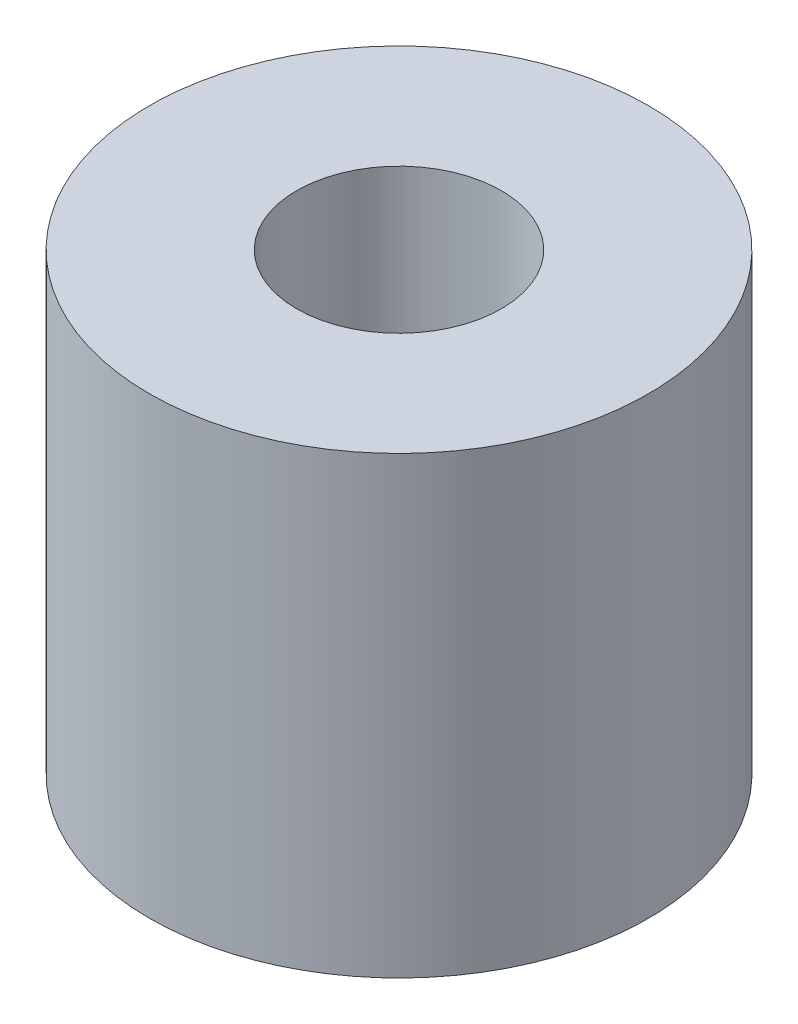
from build123d import *

# Parameters (mm, degrees)
SKETCH11_R          = 3.9
SKETCH11_R_2        = 1.6
BOSS_EXTRUDE6_DEPTH = 7.1


with BuildPart() as part:
    # Sketch11 → Boss-Extrude6 (new body)
    with BuildSketch(Plane(origin=(0, 0, 0), x_dir=(1, 0, 0), z_dir=(0, 1, 0))):
        Circle(SKETCH11_R)
        Circle(SKETCH11_R_2, mode=Mode.SUBTRACT)
    extrude(amount=BOSS_EXTRUDE6_DEPTH)


solid = part.part
